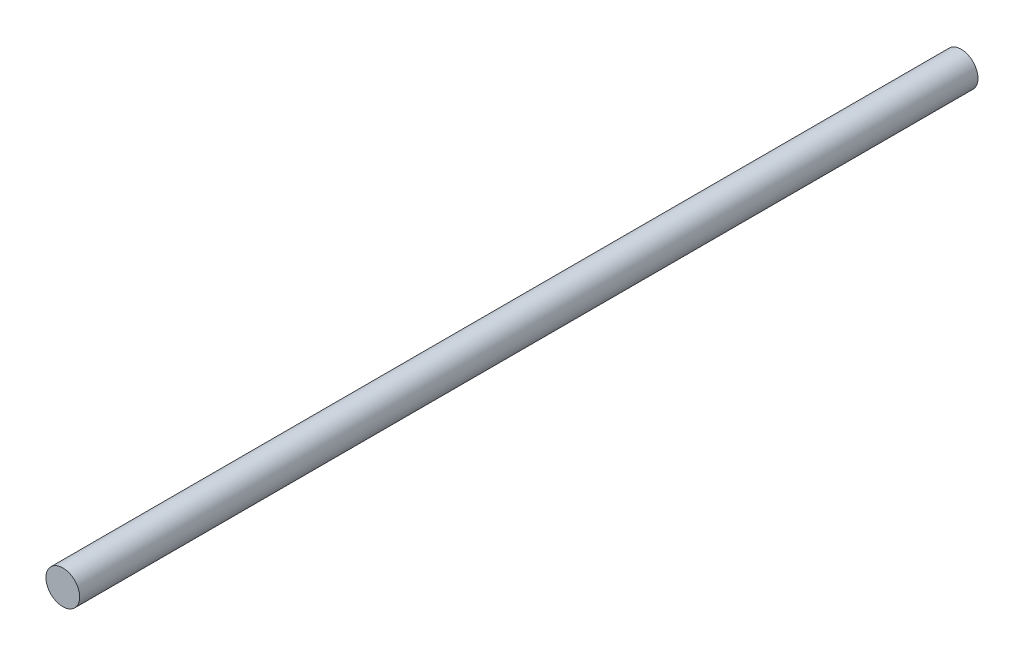
from build123d import *

# Parameters (mm, degrees)
SKETCH2_R           = 2.38125
BOSS_EXTRUDE1_DEPTH = 127


with BuildPart() as part:
    # Sketch2 → Boss-Extrude1 (new body)
    with BuildSketch(Plane.XY):
        Circle(SKETCH2_R)
    extrude(amount=-BOSS_EXTRUDE1_DEPTH)


solid = part.part
